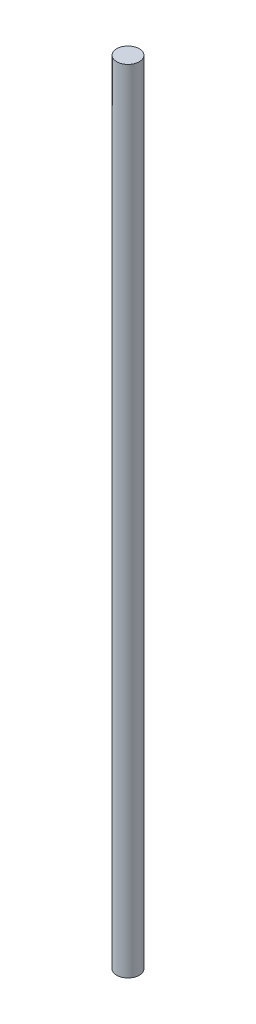
from build123d import *

# Parameters (mm, degrees)
ESBO_O1_R                = 4
RESSALTO_EXTRUS_O1_DEPTH = 140.25


with BuildPart() as part:
    # Esboço1 → Ressalto-extrusão1 (new body, symmetric)
    with BuildSketch(Plane(origin=(0, 0, 0), x_dir=(1, 0, 0), z_dir=(0, 1, 0))):
        Circle(ESBO_O1_R)
    extrude(amount=RESSALTO_EXTRUS_O1_DEPTH, both=True)


solid = part.part
